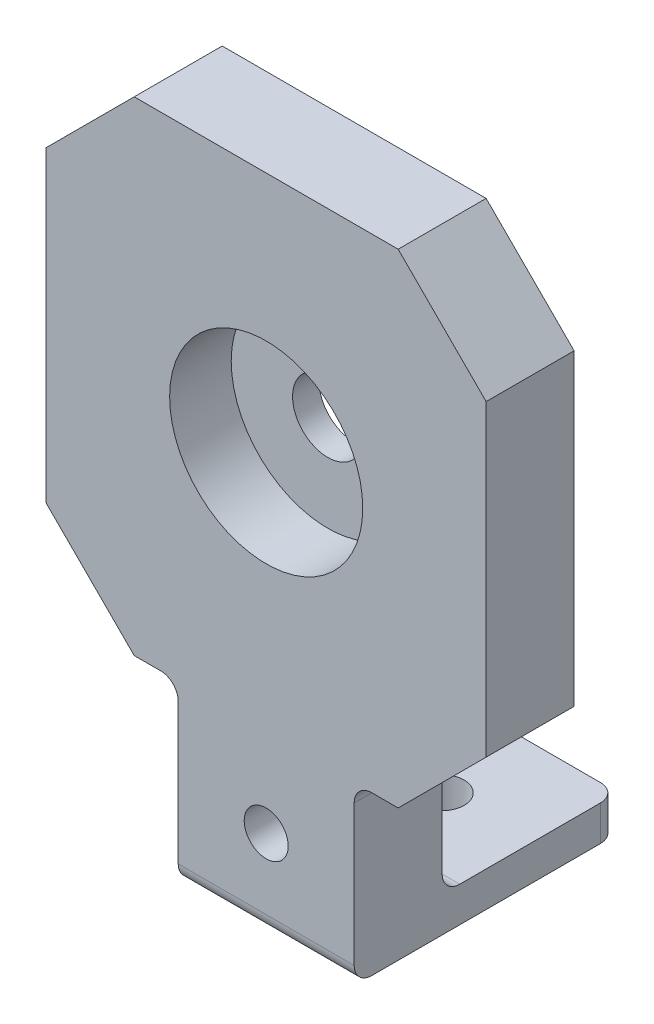
from build123d import *

# Parameters (mm, degrees)
SCHIZZO1_R                   = 4
ESTRUSIONE_ESTRUSIONE1_DEPTH = 10
SMUSSO1_SIZE                 = 10
SCHIZZO3_R                   = 10.975
TAGLIO_ESTRUSIONE1_DEPTH     = 7
SCHIZZO4_W                   = 20
SCHIZZO4_H                   = 4
ESTRUSIONE_ESTRUSIONE2_DEPTH = 20
RACCORDO1_R                  = 2
SCHIZZO5_R                   = 2.5
TAGLIO_ESTRUSIONE2_DEPTH     = 20
SCHIZZO6_R                   = 2.5
TAGLIO_ESTRUSIONE3_DEPTH     = 11


with BuildPart() as part:
    # Schizzo1 → Estrusione-Estrusione1 (new body)
    with BuildSketch(Plane.XY):
        Polygon((-25, 20), (-10, 20), (-10, 0), (10, 0), (10, 20), (25, 20), (25, 75), (-25, 75), align=None)
        with Locations((0, 47.5)):
            Circle(SCHIZZO1_R, mode=Mode.SUBTRACT)
    extrude(amount=ESTRUSIONE_ESTRUSIONE1_DEPTH)

    # Smusso1
    smusso1_edges = [part.edges().sort_by_distance(p)[0] for p in [
        (25, 20, 5),
        (-25, 20, 5),
        (-25, 75, 5),
        (25, 75, 5),
    ]]
    chamfer(smusso1_edges, length=SMUSSO1_SIZE)

    # Schizzo3 → Taglio-Estrusione1 (cut)
    with BuildSketch(Plane.XY.offset(10)):
        with Locations((0, 47.5)):
            Circle(SCHIZZO3_R)
    extrude(amount=-TAGLIO_ESTRUSIONE1_DEPTH, mode=Mode.SUBTRACT)

    # Schizzo4 → Estrusione-Estrusione2 (add)
    with BuildSketch(Plane(origin=(0, 0, 0), x_dir=(-1, 0, 0), z_dir=(0, 0, -1))):
        with Locations((0, 2)):
            Rectangle(SCHIZZO4_W, SCHIZZO4_H)
    extrude(amount=ESTRUSIONE_ESTRUSIONE2_DEPTH)

    # Raccordo1
    raccordo1_edges = [part.edges().sort_by_distance(p)[0] for p in [
        (10, 20, 5),
        (-10, 20, 5),
        (0, 0, 10),
        (0, 4, 0),
        (10, 2, -20),
        (-10, 2, -20),
    ]]
    fillet(raccordo1_edges, radius=RACCORDO1_R)

    # Schizzo5 → Taglio-Estrusione2 (cut)
    with BuildSketch(Plane(origin=(0, 4, 0), x_dir=(1, 0, 0), z_dir=(0, 1, 0))):
        with Locations((0, 10)):
            Circle(SCHIZZO5_R)
    extrude(amount=-TAGLIO_ESTRUSIONE2_DEPTH, mode=Mode.SUBTRACT)

    # Schizzo6 → Taglio-Estrusione3 (cut, through all)
    with BuildSketch(Plane(origin=(0, 0, 0), x_dir=(-1, 0, 0), z_dir=(0, 0, -1))):
        with Locations((0, 10)):
            Circle(SCHIZZO6_R)
    extrude(amount=-TAGLIO_ESTRUSIONE3_DEPTH, mode=Mode.SUBTRACT)


solid = part.part
